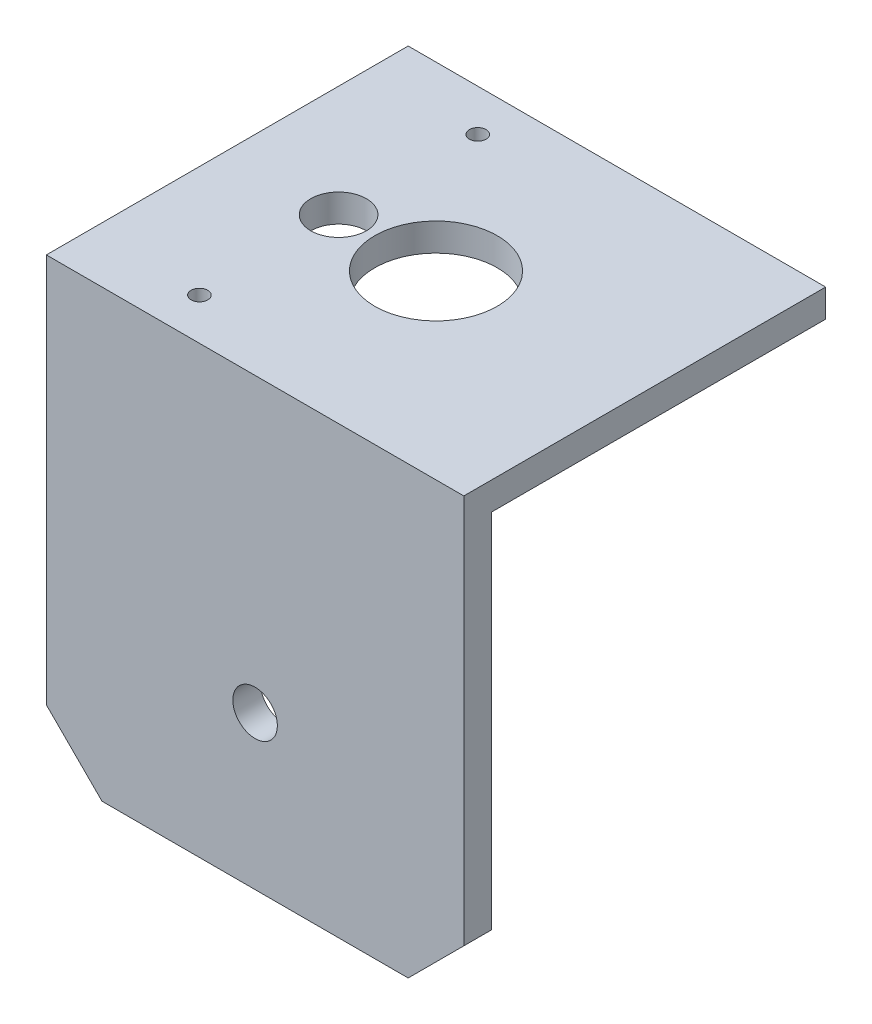
from build123d import *

# Parameters (mm, degrees)
SKETCH1_W           = 75
SKETCH1_H           = 65
SKETCH1_R           = 5
SKETCH1_R_2         = 11
SKETCH1_R_3         = 1.5
BOSS_EXTRUDE1_DEPTH = 5
SKETCH2_W           = 75
SKETCH2_H           = 5
BOSS_EXTRUDE2_DEPTH = 75
CUT_EXTRUDE1_REACH  = 67
CUT_EXTRUDE2_REACH  = 7
CUT_EXTRUDE3_REACH  = 67
SKETCH5_R           = 4
CUT_EXTRUDE4_REACH  = 67
SKETCH6_R           = 2.5
CUT_EXTRUDE5_REACH  = 7


with BuildPart() as part:
    # Sketch1 → Boss-Extrude1 (new body)
    with BuildSketch(Plane(origin=(0, 0, 0), x_dir=(1, 0, 0), z_dir=(0, 1, 0))):
        Rectangle(SKETCH1_W, SKETCH1_H)
        with Locations((-17.5, 0)):
            Circle(SKETCH1_R, mode=Mode.SUBTRACT)
        Circle(SKETCH1_R_2, mode=Mode.SUBTRACT)
        with Locations((-17.5, -25)):
            Circle(SKETCH1_R_3, mode=Mode.SUBTRACT)
        with Locations((-17.5, 25)):
            Circle(SKETCH1_R_3, mode=Mode.SUBTRACT)
    extrude(amount=BOSS_EXTRUDE1_DEPTH)

    # Sketch2 → Boss-Extrude2 (add)
    with BuildSketch(Plane.XZ):
        with Locations((0, 30)):
            Rectangle(SKETCH2_W, SKETCH2_H)
        with Locations((0, -30)):
            Rectangle(SKETCH2_W, SKETCH2_H)
    extrude(amount=BOSS_EXTRUDE2_DEPTH)

    # Sketch3 → Cut-Extrude1 (cut, up to next)
    with BuildSketch(Plane.XY.offset(32.5), mode=Mode.PRIVATE) as cut_extrude1_sk1:
        Polygon((-37.5, -75), (-27.5, -75), (-37.5, -65), align=None)
    cut_extrude1_tool1 = extrude(cut_extrude1_sk1.sketch, amount=-CUT_EXTRUDE1_REACH, mode=Mode.PRIVATE) & part.part
    add(cut_extrude1_tool1.solids().sort_by_distance((-34.166667, -71.666667, 32.5))[0], mode=Mode.SUBTRACT)
    # Sketch3 → Cut-Extrude1 (cut, up to next)
    with BuildSketch(Plane.XY.offset(32.5), mode=Mode.PRIVATE) as cut_extrude1_sk2:
        Polygon((37.5, -75), (37.5, -65), (27.5, -75), align=None)
    cut_extrude1_tool2 = extrude(cut_extrude1_sk2.sketch, amount=-CUT_EXTRUDE1_REACH, mode=Mode.PRIVATE) & part.part
    add(cut_extrude1_tool2.solids().sort_by_distance((34.166667, -71.666667, 32.5))[0], mode=Mode.SUBTRACT)

    # Sketch4 → Cut-Extrude2 (cut, up to next)
    with BuildSketch(Plane.XY.offset(-27.5), mode=Mode.PRIVATE) as cut_extrude2_sk1:
        Polygon((-37.5, -65), (-37.5, -75), (-27.5, -75), align=None)
    cut_extrude2_tool1 = extrude(cut_extrude2_sk1.sketch, amount=-CUT_EXTRUDE2_REACH, mode=Mode.PRIVATE) & part.part
    add(cut_extrude2_tool1.solids().sort_by_distance((-34.166667, -71.666667, -27.5))[0], mode=Mode.SUBTRACT)
    # Sketch4 → Cut-Extrude2 (cut, up to next)
    with BuildSketch(Plane.XY.offset(-27.5), mode=Mode.PRIVATE) as cut_extrude2_sk2:
        Polygon((37.5, -65), (27.5, -75), (37.5, -75), align=None)
    cut_extrude2_tool2 = extrude(cut_extrude2_sk2.sketch, amount=-CUT_EXTRUDE2_REACH, mode=Mode.PRIVATE) & part.part
    add(cut_extrude2_tool2.solids().sort_by_distance((34.166667, -71.666667, -27.5))[0], mode=Mode.SUBTRACT)

    # Sketch5 → Cut-Extrude3 (cut, up to next)
    with BuildSketch(Plane.XY.offset(32.5), mode=Mode.PRIVATE) as cut_extrude3_sk1:
        with Locations((0, -47.5)):
            Circle(SKETCH5_R)
    cut_extrude3_tool1 = extrude(cut_extrude3_sk1.sketch, amount=-CUT_EXTRUDE3_REACH, mode=Mode.PRIVATE) & part.part
    add(cut_extrude3_tool1.solids().sort_by_distance((0, -47.5, 32.5))[0], mode=Mode.SUBTRACT)

    # Sketch6 → Cut-Extrude4 (cut, up to next)
    with BuildSketch(Plane(origin=(0, 0, -32.5), x_dir=(-1, 0, 0), z_dir=(0, 0, -1)), mode=Mode.PRIVATE) as cut_extrude4_sk1:
        with Locations((0, -47.5)):
            Circle(SKETCH6_R)
    cut_extrude4_tool1 = extrude(cut_extrude4_sk1.sketch, amount=-CUT_EXTRUDE4_REACH, mode=Mode.PRIVATE) & part.part
    add(cut_extrude4_tool1.solids().sort_by_distance((0, -47.5, -32.5))[0], mode=Mode.SUBTRACT)

    # Sketch7 → Cut-Extrude5 (cut, up to next)
    with BuildSketch(Plane.XY.offset(-27.5), mode=Mode.PRIVATE) as cut_extrude5_sk1:
        Polygon((-37.5, 0), (37.5, 0), (37.5, -65), (27.5, -75), (-27.5, -75), (-37.5, -65), align=None)
    cut_extrude5_tool1 = extrude(cut_extrude5_sk1.sketch, amount=-CUT_EXTRUDE5_REACH, mode=Mode.PRIVATE) & part.part
    add(cut_extrude5_tool1.solids().sort_by_distance((0, -36.881599, -27.5))[0], mode=Mode.SUBTRACT)


solid = part.part
